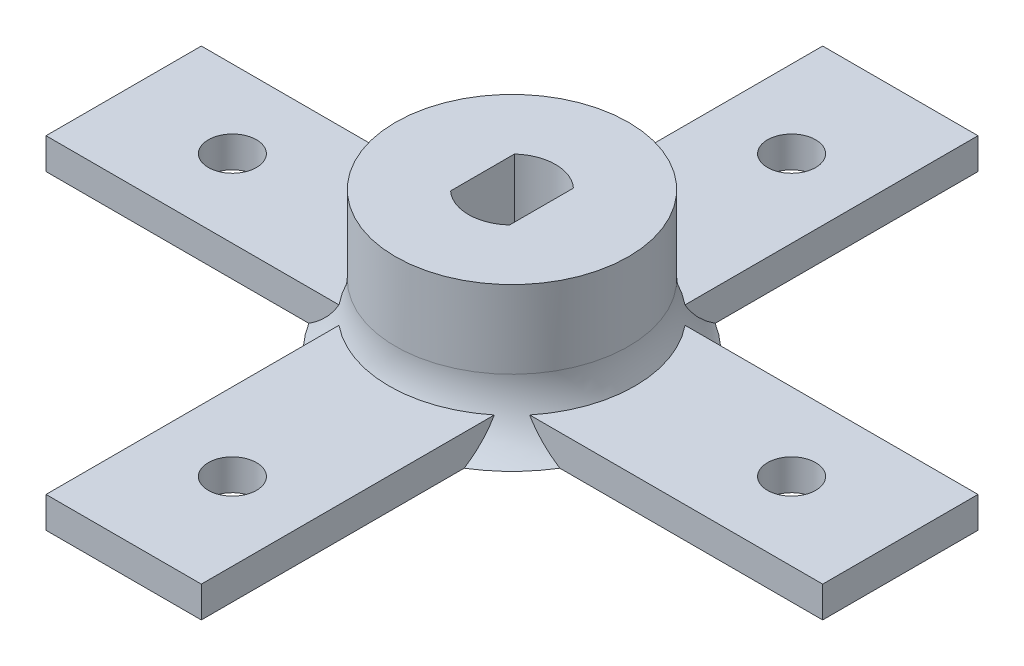
from build123d import *

# Parameters (mm, degrees)
CROQUIS1_R              = 7.5
EXTRUIR1_DEPTH          = 10
EXTRUIR2_DEPTH          = 10
CROQUIS3_R              = 30
EXTRUIR3_DEPTH          = 9
REDONDEO1_R             = 5
EXTRUIR4_DEPTH          = 10
REDONDEO2_R             = 2
CROQUIS5_R              = 39.877660951
CORTAR_EXTRUIR1_DEPTH   = 10
CROQUIS7_W              = 10
CROQUIS7_H              = 50
SALIENTE_EXTRUIR1_DEPTH = 2
CROQUIS8_W              = 50
CROQUIS8_H              = 10
SALIENTE_EXTRUIR2_DEPTH = 2
CROQUIS10_R             = 1.55
CORTAR_EXTRUIR2_DEPTH   = 2


with BuildPart() as part:
    # Croquis1 → Extruir1 (new body)
    with BuildSketch(Plane(origin=(0, 0, 0), x_dir=(1, 0, 0), z_dir=(0, 1, 0))):
        Circle(CROQUIS1_R)
    extrude(amount=EXTRUIR1_DEPTH)

    # Croquis2 → Extruir2 (cut)
    with BuildSketch(Plane(origin=(0, 10, 0), x_dir=(1, 0, 0), z_dir=(0, 1, 0))):
        with BuildLine():
            Line((-1.9, 2.05669638), (-1.9, -2.05669638))
            ThreePointArc((-1.9, -2.05669638), (0, -2.8), (1.9, -2.05669638))
            Line((1.9, -2.05669638), (1.9, 2.05669638))
            ThreePointArc((1.9, 2.05669638), (0, 2.8), (-1.9, 2.05669638))
        make_face()
    extrude(amount=-EXTRUIR2_DEPTH, mode=Mode.SUBTRACT)

    # Croquis3 → Extruir3 (add)
    with BuildSketch(Plane.XZ):
        Circle(CROQUIS3_R)
    extrude(amount=EXTRUIR3_DEPTH)

    # Redondeo1
    redondeo1_edges = [part.edges().sort_by_distance(p)[0] for p in [
        (-7.5, 0, 0),
    ]]
    fillet(redondeo1_edges, radius=REDONDEO1_R)

    # Croquis4 → Extruir4 (cut)
    with BuildSketch(Plane(origin=(0, 0, 0), x_dir=(1, 0, 0), z_dir=(0, 1, 0))):
        with BuildLine():
            ThreePointArc((-13.896428557, -5.647058824), (-10.606601718, -10.606601718), (-5.647058824, -13.896428557))
            ThreePointArc((-5.647058824, -13.896428557), (-2.209821435, -22.039548299), (-10.352941176, -25.476785688))
            ThreePointArc((-10.352941176, -25.476785688), (-19.445436483, -19.445436483), (-25.476785688, -10.352941176))
            ThreePointArc((-25.476785688, -10.352941176), (-22.039548299, -2.209821435), (-13.896428557, -5.647058824))
        make_face()
        with BuildLine():
            ThreePointArc((-5.647058824, 13.896428557), (-2.209821435, 22.039548299), (-10.352941176, 25.476785688))
            ThreePointArc((-10.352941176, 25.476785688), (-19.445436483, 19.445436483), (-25.476785688, 10.352941176))
            ThreePointArc((-25.476785688, 10.352941176), (-22.039548299, 2.209821435), (-13.896428557, 5.647058824))
            ThreePointArc((-13.896428557, 5.647058824), (-10.606601718, 10.606601718), (-5.647058824, 13.896428557))
        make_face()
        with BuildLine():
            ThreePointArc((10.352941176, 25.476785688), (2.209821435, 22.039548299), (5.647058824, 13.896428557))
            ThreePointArc((5.647058824, 13.896428557), (10.606601718, 10.606601718), (13.896428557, 5.647058824))
            ThreePointArc((13.896428557, 5.647058824), (22.039548299, 2.209821435), (25.476785688, 10.352941176))
            ThreePointArc((25.476785688, 10.352941176), (19.445436483, 19.445436483), (10.352941176, 25.476785688))
        make_face()
        with BuildLine():
            ThreePointArc((5.647058824, -13.896428557), (2.209821435, -22.039548299), (10.352941176, -25.476785688))
            ThreePointArc((10.352941176, -25.476785688), (19.445436483, -19.445436483), (25.476785688, -10.352941176))
            ThreePointArc((25.476785688, -10.352941176), (22.039548299, -2.209821435), (13.896428557, -5.647058824))
            ThreePointArc((13.896428557, -5.647058824), (10.606601718, -10.606601718), (5.647058824, -13.896428557))
        make_face()
    extrude(amount=-EXTRUIR4_DEPTH, mode=Mode.SUBTRACT)

    # Redondeo2
    redondeo2_edges = [part.edges().sort_by_distance(p)[0] for p in [
        (-30, 0, 0),
        (-30, -9, 0),
    ]]
    fillet(redondeo2_edges, radius=REDONDEO2_R)

    # Croquis5 → Cortar-Extruir1 (cut)
    with BuildSketch(Plane.XZ.offset(9)):
        Circle(CROQUIS5_R)
    extrude(amount=-CORTAR_EXTRUIR1_DEPTH, mode=Mode.SUBTRACT)

    # Croquis7 → Saliente-Extruir1 (add)
    with BuildSketch(Plane.XZ.offset(-1)):
        Rectangle(CROQUIS7_W, CROQUIS7_H)
    extrude(amount=-SALIENTE_EXTRUIR1_DEPTH)

    # Croquis8 → Saliente-Extruir2 (add)
    with BuildSketch(Plane.XZ.offset(-1)):
        Rectangle(CROQUIS8_W, CROQUIS8_H)
    extrude(amount=-SALIENTE_EXTRUIR2_DEPTH)

    # Croquis10 → Cortar-Extruir2 (cut)
    with BuildSketch(Plane.XZ.offset(-1)):
        with Locations((-18, 0)):
            Circle(CROQUIS10_R)
        with Locations((0, 18)):
            Circle(CROQUIS10_R)
        with Locations((0, -18)):
            Circle(CROQUIS10_R)
        with Locations((18, 0)):
            Circle(CROQUIS10_R)
    extrude(amount=-CORTAR_EXTRUIR2_DEPTH, mode=Mode.SUBTRACT)


solid = part.part
